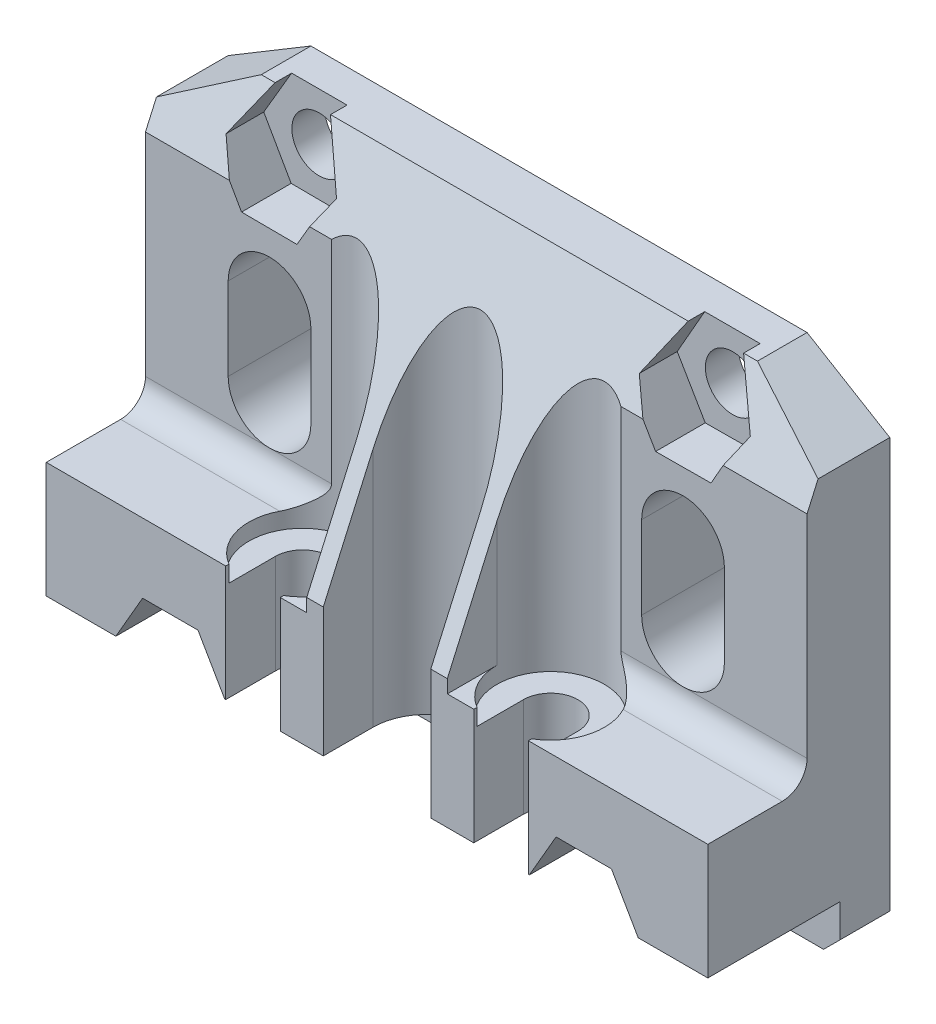
from build123d import *

# Parameters (mm, degrees)
SKETCH1_W           = 40
SKETCH1_H           = 28.8
BOSS_EXTRUDE1_DEPTH = 11
CHAMFER2_SIZE       = 8
CHAMFER2_SIZE2      = 18
SKETCH10_W          = 13.5
SKETCH10_H          = 18.8
CUT_EXTRUDE7_DEPTH  = 6
FILLET1_R           = 1.5
SKETCH11_W          = 40
SKETCH11_H          = 3
CUT_EXTRUDE8_DEPTH  = 8
CUT_EXTRUDE9_DEPTH  = 18.8
CUT_EXTRUDE10_DEPTH = 11
CUT_EXTRUDE2_DEPTH  = 30
SKETCH2_R           = 1.65
CUT_EXTRUDE1_DEPTH  = 12
CUT_EXTRUDE4_DEPTH  = 9
SKETCH15_R          = 3.25
CUT_EXTRUDE12_DEPTH = 1
CUT_EXTRUDE13_DEPTH = 6
CHAMFER4_SIZE       = 3
CHAMFER4_SIZE2      = 5
CHAMFER5_SIZE       = 5
CHAMFER5_SIZE2      = 3
CUT_EXTRUDE11_DEPTH = 9.4
CHAMFER8_SIZE       = 1


with BuildPart() as part:
    # Sketch1 → Boss-Extrude1 (new body)
    with BuildSketch(Plane.XY):
        with Locations((0, 14.4)):
            Rectangle(SKETCH1_W, SKETCH1_H)
    extrude(amount=BOSS_EXTRUDE1_DEPTH)

    # Chamfer2
    chamfer2_edges = [part.edges().sort_by_distance(p)[0] for p in [
        (0, 28.8, 11),
    ]]
    chamfer2_side = [part.faces().sort_by_distance(p)[0] for p in [
        (0, 28.8, 5.5),
    ]]
    chamfer(chamfer2_edges, length=CHAMFER2_SIZE, length2=CHAMFER2_SIZE2, reference=chamfer2_side[0])

    # Sketch10 → Cut-Extrude7 (cut)
    with BuildSketch(Plane.XY.offset(11)):
        with Locations((-13.25, 19.4)):
            Rectangle(SKETCH10_W, SKETCH10_H)
        with Locations((13.25, 19.4)):
            Rectangle(SKETCH10_W, SKETCH10_H)
    extrude(amount=-CUT_EXTRUDE7_DEPTH, mode=Mode.SUBTRACT)

    # Fillet1
    fillet1_edges = [part.edges().sort_by_distance(p)[0] for p in [
        (-13.25, 10, 5),
        (13.25, 10, 5),
    ]]
    fillet(fillet1_edges, radius=FILLET1_R)

    # Sketch11 → Cut-Extrude8 (cut)
    with BuildSketch(Plane.XY.offset(11)):
        with Locations((0, 1.5)):
            Rectangle(SKETCH11_W, SKETCH11_H)
    extrude(amount=-CUT_EXTRUDE8_DEPTH, mode=Mode.SUBTRACT)

    # Sketch12 → Cut-Extrude9 (cut)
    with BuildSketch(Plane(origin=(0, 28.8, 0), x_dir=(1, 0, 0), z_dir=(0, 1, 0))):
        with BuildLine():
            Line((-4.25, -8), (-4.25, -11))
            Line((-4.25, -11), (-10.75, -11))
            Line((-10.75, -11), (-10.75, -8))
            ThreePointArc((-10.75, -8), (-7.5, -4.75), (-4.25, -8))
        make_face()
    cut_extrude9 = extrude(amount=-CUT_EXTRUDE9_DEPTH, mode=Mode.SUBTRACT)

    # Sketch13 → Cut-Extrude10 (cut, through all)
    with BuildSketch(Plane(origin=(0, 10, 0), x_dir=(1, 0, 0), z_dir=(0, 1, 0))):
        with BuildLine():
            Line((-9.15, -8), (-9.15, -11))
            Line((-9.15, -11), (-5.85, -11))
            Line((-5.85, -11), (-5.85, -8))
            ThreePointArc((-5.85, -8), (-7.5, -6.35), (-9.15, -8))
        make_face()
    cut_extrude10 = extrude(amount=-CUT_EXTRUDE10_DEPTH, mode=Mode.SUBTRACT)

    # Sketch3 → Cut-Extrude2 (cut)
    with BuildSketch(Plane.XZ):
        with BuildLine():
            Line((-3.25, 8), (-3.25, 11))
            Line((-3.25, 11), (3.25, 11))
            Line((3.25, 11), (3.25, 8))
            ThreePointArc((3.25, 8), (0, 4.75), (-3.25, 8))
        make_face()
    extrude(amount=-CUT_EXTRUDE2_DEPTH, mode=Mode.SUBTRACT)

    # Sketch2 → Cut-Extrude1 (cut, through all)
    with BuildSketch(Plane.XY.offset(11)):
        with Locations((-12.5, 2.9)):
            Circle(SKETCH2_R)
        with Locations((12.5, 2.9)):
            Circle(SKETCH2_R)
        with Locations((12.5, 25.9)):
            Circle(SKETCH2_R)
        with Locations((-12.5, 25.9)):
            Circle(SKETCH2_R)
    extrude(amount=-CUT_EXTRUDE1_DEPTH, mode=Mode.SUBTRACT)

    # Sketch5 → Cut-Extrude4 (cut)
    with BuildSketch(Plane.XY.offset(11)):
        Polygon((-13.825512835, 29.376278709), (-11.142302486, 29.376278709), (-9.151427839, 25.880054666), (-10.842987085, 22.990078775), (-14.191559246, 23.010024109), (-15.848572161, 25.919945334), align=None)
        Polygon((11.142302486, 29.376278709), (13.825512835, 29.376278709), (15.848572161, 25.919945334), (14.191559246, 23.010024109), (10.842987085, 22.990078775), (9.151427839, 25.880054666), align=None)
    extrude(amount=-CUT_EXTRUDE4_DEPTH, mode=Mode.SUBTRACT)

    # Sketch15 → Cut-Extrude12 (cut)
    with BuildSketch(Plane(origin=(0, 10, 0), x_dir=(1, 0, 0), z_dir=(0, 1, 0))):
        with Locations((-7.5, -8)):
            Circle(SKETCH15_R)
    cut_extrude12 = extrude(amount=-CUT_EXTRUDE12_DEPTH, mode=Mode.SUBTRACT)

    # Sketch16 → Cut-Extrude13 (cut, through all)
    with BuildSketch(Plane.XY.offset(5)):
        with BuildLine():
            Line((-15, 14), (-15, 19))
            ThreePointArc((-15, 19), (-12.5, 21.5), (-10, 19))
            Line((-10, 19), (-10, 14))
            ThreePointArc((-10, 14), (-12.5, 11.5), (-15, 14))
        make_face()
    cut_extrude13 = extrude(amount=-CUT_EXTRUDE13_DEPTH, mode=Mode.SUBTRACT)

    # Mirror1: Cut-Extrude9, Cut-Extrude10, Cut-Extrude12, Cut-Extrude13 across plane
    add(cut_extrude9.mirror(Plane(origin=(0, 0, 0), x_dir=(0, 0, 1), z_dir=(1, 0, 0))), mode=Mode.SUBTRACT)
    add(cut_extrude10.mirror(Plane(origin=(0, 0, 0), x_dir=(0, 0, 1), z_dir=(1, 0, 0))), mode=Mode.SUBTRACT)
    add(cut_extrude12.mirror(Plane(origin=(0, 0, 0), x_dir=(0, 0, 1), z_dir=(1, 0, 0))), mode=Mode.SUBTRACT)
    add(cut_extrude13.mirror(Plane(origin=(0, 0, 0), x_dir=(0, 0, 1), z_dir=(1, 0, 0))), mode=Mode.SUBTRACT)

    # Chamfer4
    chamfer4_edges = [part.edges().sort_by_distance(p)[0] for p in [
        (20, 28.8, 1.5),
    ]]
    chamfer4_side = [part.faces().sort_by_distance(p)[0] for p in [
        (20, 12.613389716, 3.722385656),
    ]]
    chamfer(chamfer4_edges, length=CHAMFER4_SIZE, length2=CHAMFER4_SIZE2, reference=chamfer4_side[0])

    # Chamfer5
    chamfer5_edges = [part.edges().sort_by_distance(p)[0] for p in [
        (-20, 28.8, 1.5),
    ]]
    chamfer5_side = [part.faces().sort_by_distance(p)[0] for p in [
        (-2.670324549, 28.8, 1.43187018),
    ]]
    chamfer(chamfer5_edges, length=CHAMFER5_SIZE, length2=CHAMFER5_SIZE2, reference=chamfer5_side[0])

    # Sketch14 → Cut-Extrude11 (cut)
    with BuildSketch(Plane.XY.offset(11)):
        Polygon((-9.151368439, 2.9), (-10.825684219, 5.8), (-14.174315781, 5.8), (-15.848631561, 2.9), (-14.174315781, 0), (-10.825684219, 0), align=None)
        Polygon((15.848631561, 2.9), (14.174315781, 5.8), (10.825684219, 5.8), (9.151368439, 2.9), (10.825684219, 0), (14.174315781, 0), align=None)
    extrude(amount=-CUT_EXTRUDE11_DEPTH, mode=Mode.SUBTRACT)

    # Chamfer8
    chamfer8_edges = [part.edges().sort_by_distance(p)[0] for p in [
        (20, 0, 1.5),
        (-20, 0, 1.5),
    ]]
    chamfer(chamfer8_edges, length=CHAMFER8_SIZE)


solid = part.part
